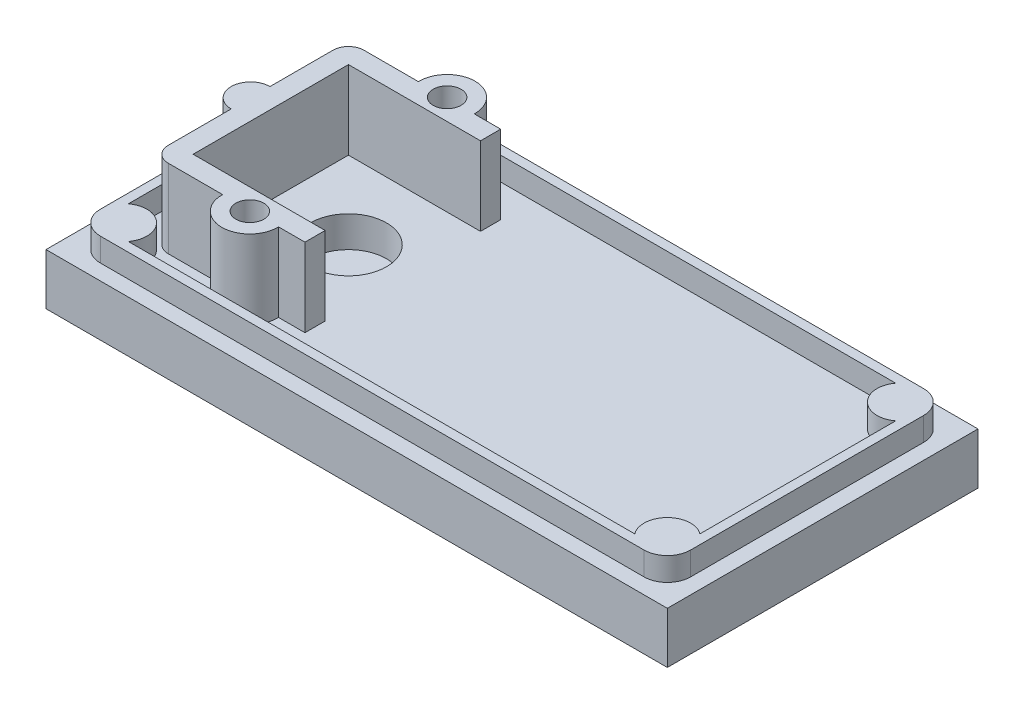
from build123d import *

# Parameters (mm, degrees)
SKETCH1_W           = 40
SKETCH1_H           = 20
BOSS_EXTRUDE1_DEPTH = 3.3
BOSS_EXTRUDE2_DEPTH = 1.5
SKETCH3_R           = 2.45
CUT_EXTRUDE1_DEPTH  = 2
BOSS_EXTRUDE3_DEPTH = 5.05
SKETCH5_R           = 0.9
CUT_EXTRUDE2_DEPTH  = 4


with BuildPart() as part:
    # Sketch1 → Boss-Extrude1 (new body)
    with BuildSketch(Plane(origin=(0, 0, 0), x_dir=(1, 0, 0), z_dir=(0, 1, 0))):
        Rectangle(SKETCH1_W, SKETCH1_H)
    extrude(amount=BOSS_EXTRUDE1_DEPTH)

    # Sketch2 → Boss-Extrude2 (add)
    with BuildSketch(Plane(origin=(0, 3.3, 0), x_dir=(1, 0, 0), z_dir=(0, 1, 0))):
        with BuildLine():
            Line((-19, 7.5), (-19, -7.5))
            ThreePointArc((-19, -7.5), (-18.560660172, -8.560660172), (-17.5, -9))
            Line((-17.5, -9), (17.5, -9))
            ThreePointArc((17.5, -9), (18.560660172, -8.560660172), (19, -7.5))
            Line((19, -7.5), (19, 7.5))
            ThreePointArc((19, 7.5), (18.560660172, 8.560660172), (17.5, 9))
            Line((17.5, 9), (-17.5, 9))
            ThreePointArc((-17.5, 9), (-18.560660172, 8.560660172), (-19, 7.5))
        make_face()
        with BuildLine():
            Line((-18.4, 6.3), (-18.4, -6.3))
            ThreePointArc((-18.4, -6.3), (-16.439339828, -6.439339828), (-16.3, -8.4))
            Line((-16.3, -8.4), (16.3, -8.4))
            ThreePointArc((16.3, -8.4), (16.439339828, -6.439339828), (18.4, -6.3))
            Line((18.4, -6.3), (18.4, 6.3))
            ThreePointArc((18.4, 6.3), (16.439339828, 6.439339828), (16.3, 8.4))
            Line((16.3, 8.4), (-16.3, 8.4))
            ThreePointArc((-16.3, 8.4), (-16.439339828, 6.439339828), (-18.4, 6.3))
        make_face(mode=Mode.SUBTRACT)
    extrude(amount=BOSS_EXTRUDE2_DEPTH)

    # Sketch3 → Cut-Extrude1 (cut)
    with BuildSketch(Plane(origin=(0, 3.3, 0), x_dir=(-1, 0, 0), z_dir=(0, 1, 0))):
        with Locations((10.52883238, 0)):
            Circle(SKETCH3_R)
    extrude(amount=-CUT_EXTRUDE1_DEPTH, mode=Mode.SUBTRACT)

    # Sketch4 → Boss-Extrude3 (add)
    with BuildSketch(Plane(origin=(0, 3.3, 0), x_dir=(1, 0, 0), z_dir=(0, 1, 0))):
        with BuildLine():
            Line((-15.52883238, -5), (-7.02883238, -5))
            Line((-7.02883238, -5), (-7.02883238, -6.3))
            Line((-7.02883238, -6.3), (-8.729526959, -6.3))
            ThreePointArc((-8.729526959, -6.3), (-10.52883238, -8.15), (-12.328137802, -6.3))
            Line((-12.328137802, -6.3), (-15.82883238, -6.3))
            ThreePointArc((-15.82883238, -6.3), (-16.535939162, -6.007106781), (-16.82883238, -5.3))
            Line((-16.82883238, -5.3), (-16.82883238, -1.25))
            ThreePointArc((-16.82883238, -1.25), (-18.07883238, 0), (-16.82883238, 1.25))
            Line((-16.82883238, 1.25), (-16.82883238, 5.3))
            ThreePointArc((-16.82883238, 5.3), (-16.535939162, 6.007106781), (-15.82883238, 6.3))
            Line((-15.82883238, 6.3), (-12.328137802, 6.3))
            ThreePointArc((-12.328137802, 6.3), (-10.52883238, 8.15), (-8.729526959, 6.3))
            Line((-8.729526959, 6.3), (-7.02883238, 6.3))
            Line((-7.02883238, 6.3), (-7.02883238, 5))
            Line((-7.02883238, 5), (-15.52883238, 5))
            Line((-15.52883238, 5), (-15.52883238, -5))
        make_face()
    extrude(amount=BOSS_EXTRUDE3_DEPTH)

    # Sketch5 → Cut-Extrude2 (cut)
    with BuildSketch(Plane(origin=(0, 8.35, 0), x_dir=(-1, 0, 0), z_dir=(0, 1, 0))):
        with Locations((10.52883238, 6.35)):
            Circle(SKETCH5_R)
        with Locations((10.52883238, -6.35)):
            Circle(SKETCH5_R)
    extrude(amount=-CUT_EXTRUDE2_DEPTH, mode=Mode.SUBTRACT)


solid = part.part
